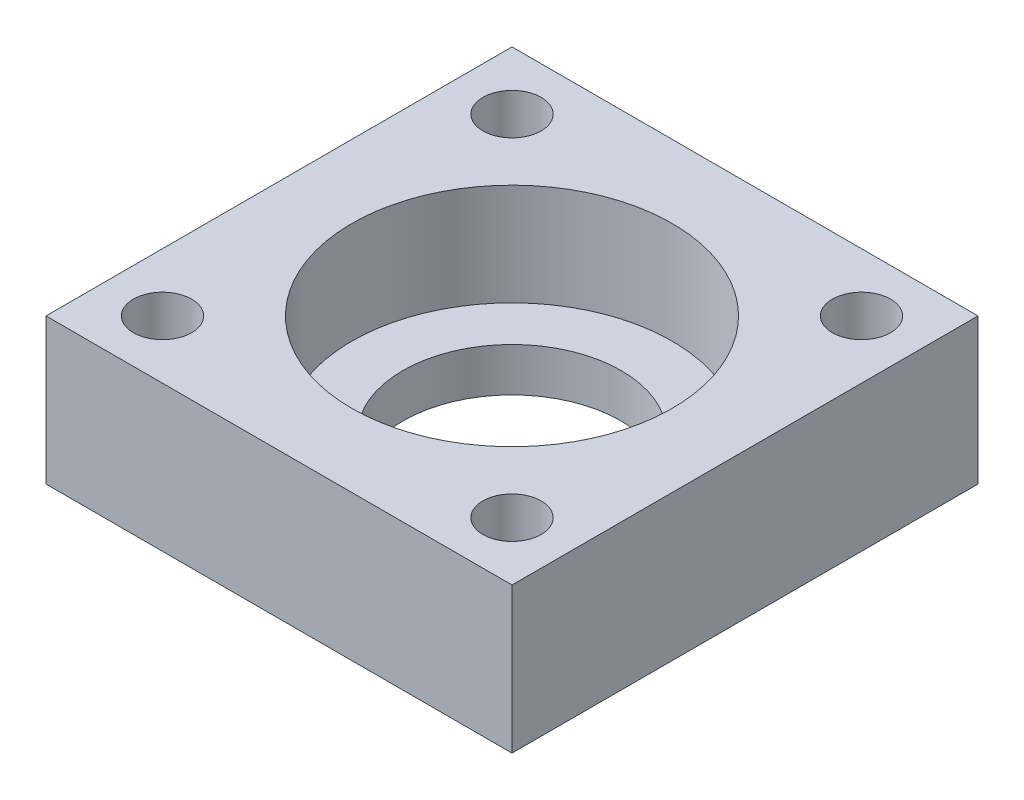
from build123d import *

# Parameters (mm, degrees)
SKETCH1_W           = 32
SKETCH1_H           = 32
BOSS_EXTRUDE1_DEPTH = 10
SKETCH2_R           = 11
CUT_EXTRUDE1_DEPTH  = 7
SKETCH3_R           = 2
SKETCH3_R_2         = 7.5
CUT_EXTRUDE2_DEPTH  = 11


with BuildPart() as part:
    # Sketch1 → Boss-Extrude1 (new body)
    with BuildSketch(Plane(origin=(0, 0, 0), x_dir=(1, 0, 0), z_dir=(0, 1, 0))):
        Rectangle(SKETCH1_W, SKETCH1_H)
    extrude(amount=BOSS_EXTRUDE1_DEPTH)

    # Sketch2 → Cut-Extrude1 (cut)
    with BuildSketch(Plane(origin=(0, 10, 0), x_dir=(1, 0, 0), z_dir=(0, 1, 0))):
        Circle(SKETCH2_R)
    extrude(amount=-CUT_EXTRUDE1_DEPTH, mode=Mode.SUBTRACT)

    # Sketch3 → Cut-Extrude2 (cut, through all)
    with BuildSketch(Plane(origin=(0, 10, 0), x_dir=(1, 0, 0), z_dir=(0, 1, 0))):
        with Locations((-12, 12)):
            Circle(SKETCH3_R)
        with Locations((12, 12)):
            Circle(SKETCH3_R)
        with Locations((12, -12)):
            Circle(SKETCH3_R)
        with Locations((-12, -12)):
            Circle(SKETCH3_R)
        Circle(SKETCH3_R_2)
    extrude(amount=-CUT_EXTRUDE2_DEPTH, mode=Mode.SUBTRACT)


solid = part.part
